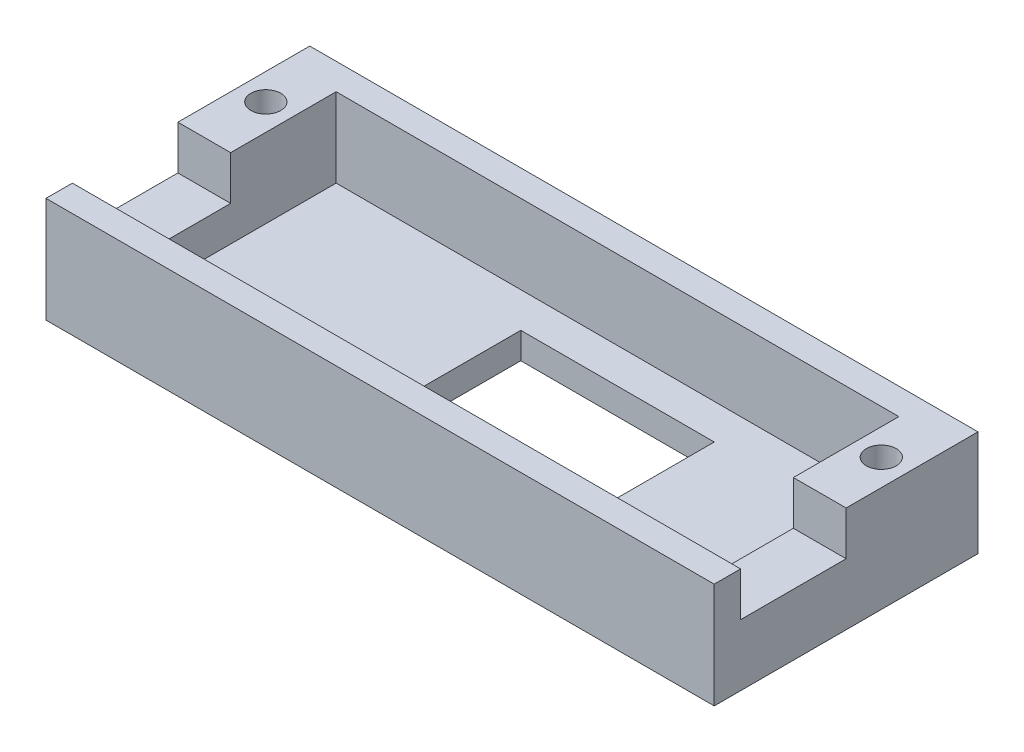
from build123d import *

# Parameters (mm, degrees)
SKETCH1_W           = 76
SKETCH1_H           = 30
BOSS_EXTRUDE1_DEPTH = 12
SKETCH2_W           = 64
SKETCH2_H           = 24
CUT_EXTRUDE1_DEPTH  = 9
SKETCH3_R           = 1.7
CUT_EXTRUDE2_DEPTH  = 20
SKETCH4_W           = 6
SKETCH4_H           = 12
CUT_EXTRUDE3_DEPTH  = 5
SKETCH5_W           = 22
SKETCH5_H           = 20
CUT_EXTRUDE4_DEPTH  = 5


with BuildPart() as part:
    # Sketch1 → Boss-Extrude1 (new body)
    with BuildSketch(Plane(origin=(0, 0, 0), x_dir=(1, 0, 0), z_dir=(0, 1, 0))):
        with Locations((38, 15)):
            Rectangle(SKETCH1_W, SKETCH1_H)
    extrude(amount=BOSS_EXTRUDE1_DEPTH)

    # Sketch2 → Cut-Extrude1 (cut)
    with BuildSketch(Plane(origin=(0, 12, 0), x_dir=(1, 0, 0), z_dir=(0, 1, 0))):
        with Locations((38, 15)):
            Rectangle(SKETCH2_W, SKETCH2_H)
    extrude(amount=-CUT_EXTRUDE1_DEPTH, mode=Mode.SUBTRACT)

    # Sketch3 → Cut-Extrude2 (cut)
    with BuildSketch(Plane(origin=(0, 12, 0), x_dir=(1, 0, 0), z_dir=(0, 1, 0))):
        with Locations((73, 22)):
            Circle(SKETCH3_R)
        with Locations((3, 22)):
            Circle(SKETCH3_R)
    extrude(amount=-CUT_EXTRUDE2_DEPTH, mode=Mode.SUBTRACT)

    # Sketch4 → Cut-Extrude3 (cut)
    with BuildSketch(Plane(origin=(0, 12, 0), x_dir=(1, 0, 0), z_dir=(0, 1, 0))):
        with Locations((73, 9)):
            Rectangle(SKETCH4_W, SKETCH4_H)
        with Locations((3, 9)):
            Rectangle(SKETCH4_W, SKETCH4_H)
    extrude(amount=-CUT_EXTRUDE3_DEPTH, mode=Mode.SUBTRACT)

    # Sketch5 → Cut-Extrude4 (cut)
    with BuildSketch(Plane(origin=(0, 3, 0), x_dir=(1, 0, 0), z_dir=(0, 1, 0))):
        with Locations((42, 13)):
            Rectangle(SKETCH5_W, SKETCH5_H)
    extrude(amount=-CUT_EXTRUDE4_DEPTH, mode=Mode.SUBTRACT)


solid = part.part
